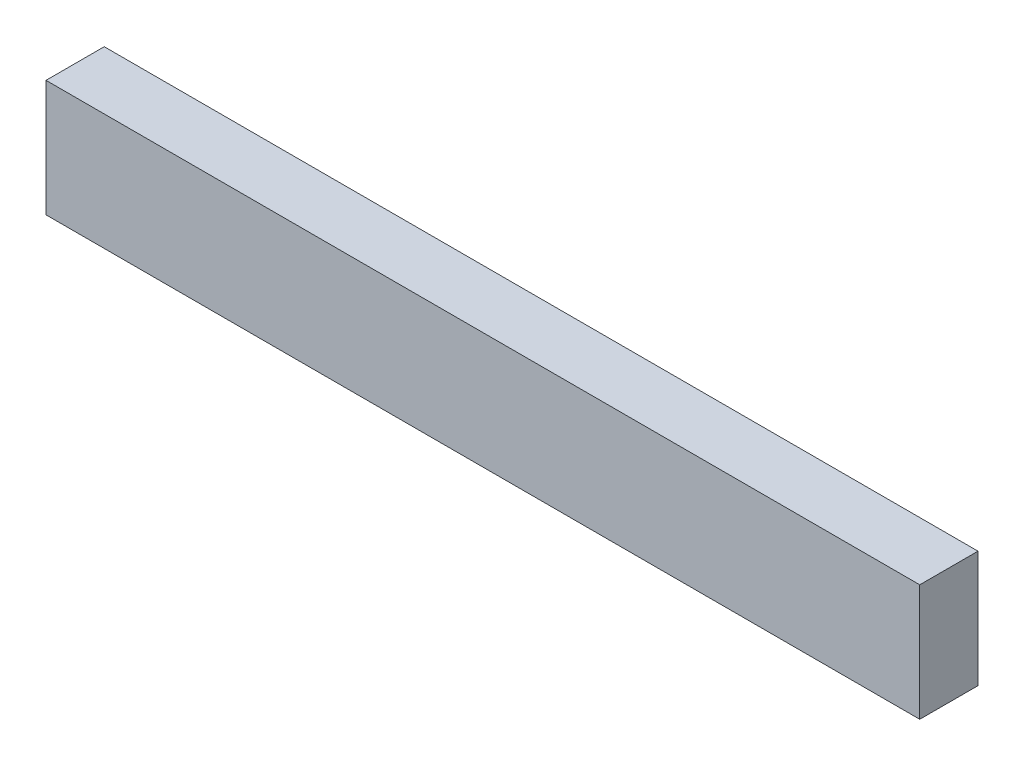
from build123d import *

# Parameters (mm, degrees)
SKETCH1_W           = 150
SKETCH1_H           = 20
BOSS_EXTRUDE1_DEPTH = 10


with BuildPart() as part:
    # Sketch1 → Boss-Extrude1 (new body)
    with BuildSketch(Plane.XY):
        Rectangle(SKETCH1_W, SKETCH1_H)
    extrude(amount=BOSS_EXTRUDE1_DEPTH)


solid = part.part
